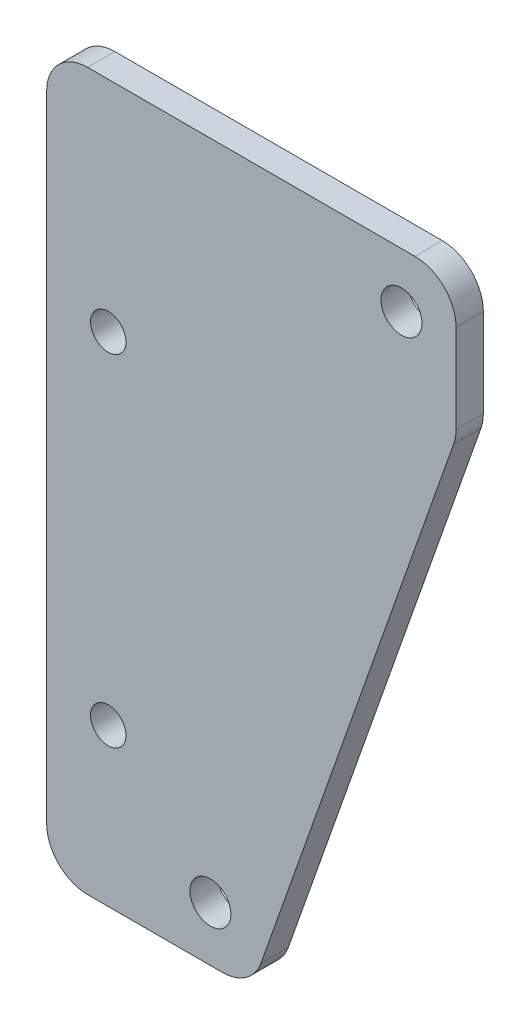
from build123d import *

# Parameters (mm, degrees)
SKETCH_1_R      = 1.5
SKETCH_1_R_2    = 1.3
EXTRUDE_1_DEPTH = 2
FILLET_1_R      = 3


with BuildPart() as part:
    # 草图1 → 凸台-拉伸1 (new body)
    with BuildSketch(Plane.XY):
        Polygon((30, 0), (0, 0), (0, -52.5), (15, -52.5), (30, -10), align=None)
        with Locations((26, -4)):
            Circle(SKETCH_1_R, mode=Mode.SUBTRACT)
        with Locations((12, -48.5)):
            Circle(SKETCH_1_R, mode=Mode.SUBTRACT)
        with Locations((4.515040622, -41)):
            Circle(SKETCH_1_R_2, mode=Mode.SUBTRACT)
        with Locations((4.515040622, -16.028894545)):
            Circle(SKETCH_1_R_2, mode=Mode.SUBTRACT)
    extrude(amount=EXTRUDE_1_DEPTH)

    # 圆角1
    fillet_1_edges = [part.edges().sort_by_distance(p)[0] for p in [
        (30, -10, 1),
        (15, -52.5, 1),
        (0, -52.5, 1),
        (0, 0, 1),
        (30, 0, 1),
    ]]
    fillet(fillet_1_edges, radius=FILLET_1_R)


solid = part.part
